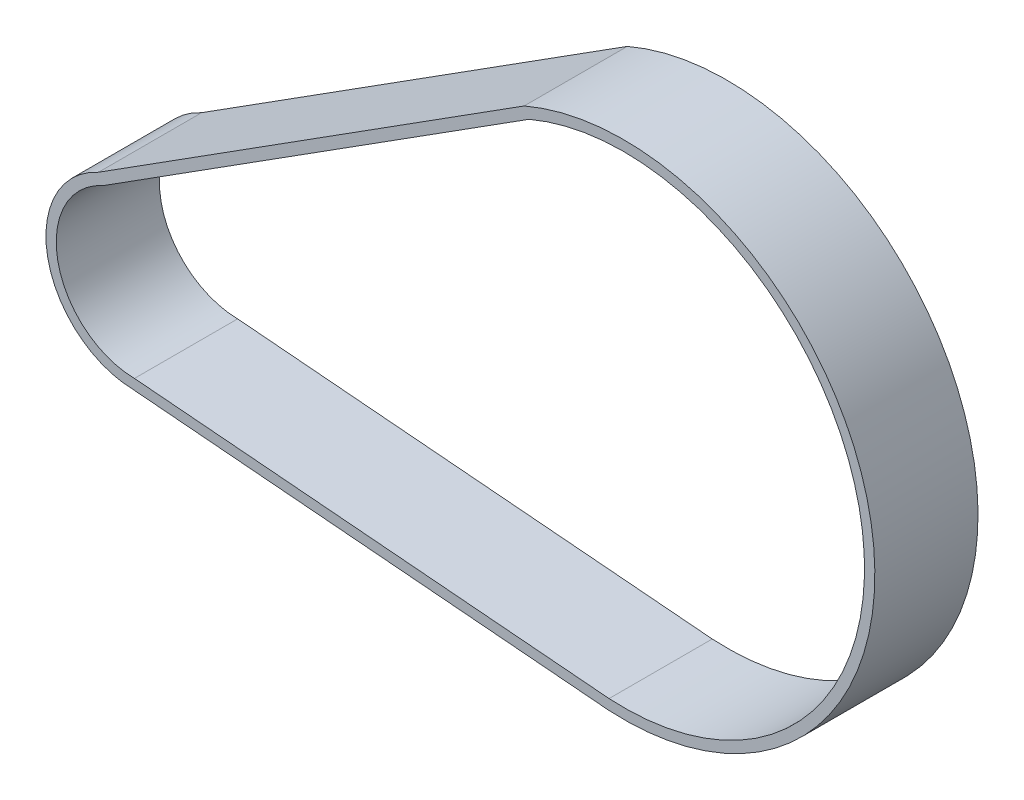
from build123d import *

# Parameters (mm, degrees)
BOSS_EXTRUDE1_DEPTH = 15


with BuildPart() as part:
    # Sketch1 → Boss-Extrude1 (new body)
    with BuildSketch(Plane.XY):
        with BuildLine():
            Line((-5.367349021, 11.840251876), (56.52765697, 51.134295925))
            ThreePointArc((56.52765697, 51.134295925), (106.958396704, 23.913997358), (68.755458093, -18.802974044))
            Line((68.755458093, -18.802974044), (-0.204046973, -12.998398549))
            ThreePointArc((-0.204046973, -12.998398549), (-12.727912321, -2.645798167), (-5.367349021, 11.840251876))
        make_face()
        with BuildLine():
            Line((-4.654955125, 10.515768768), (57.2304031, 49.803687933))
            ThreePointArc((57.2304031, 49.803687933), (105.489455803, 23.606000624), (68.864403257, -17.306839832))
            Line((68.864403257, -17.306839832), (-0.130846251, -11.499255596))
            ThreePointArc((-0.130846251, -11.499255596), (-11.264603772, -2.314887009), (-4.654955125, 10.515768768))
        make_face(mode=Mode.SUBTRACT)
    extrude(amount=BOSS_EXTRUDE1_DEPTH)


solid = part.part
